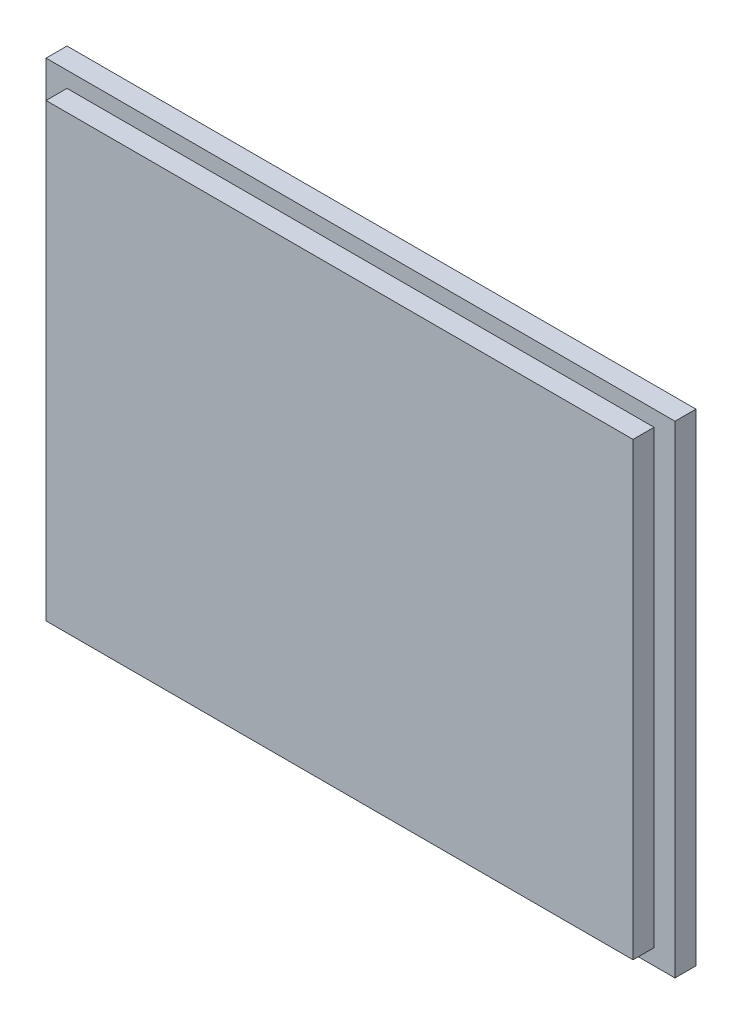
from build123d import *

# Parameters (mm, degrees)
ESBO_O1_W                = 300
ESBO_O1_H                = 230
RESSALTO_EXTRUS_O1_DEPTH = 10
ESBO_O2_W                = 280
ESBO_O2_H                = 215
RESSALTO_EXTRUS_O2_DEPTH = 10


with BuildPart() as part:
    # Esboço1 → Ressalto-extrusão1 (new body)
    with BuildSketch(Plane.XY):
        Rectangle(ESBO_O1_W, ESBO_O1_H)
    extrude(amount=RESSALTO_EXTRUS_O1_DEPTH)

    # Esboço2 → Ressalto-extrusão2 (add)
    with BuildSketch(Plane.XY.offset(10)):
        Rectangle(ESBO_O2_W, ESBO_O2_H)
    extrude(amount=RESSALTO_EXTRUS_O2_DEPTH)


solid = part.part
